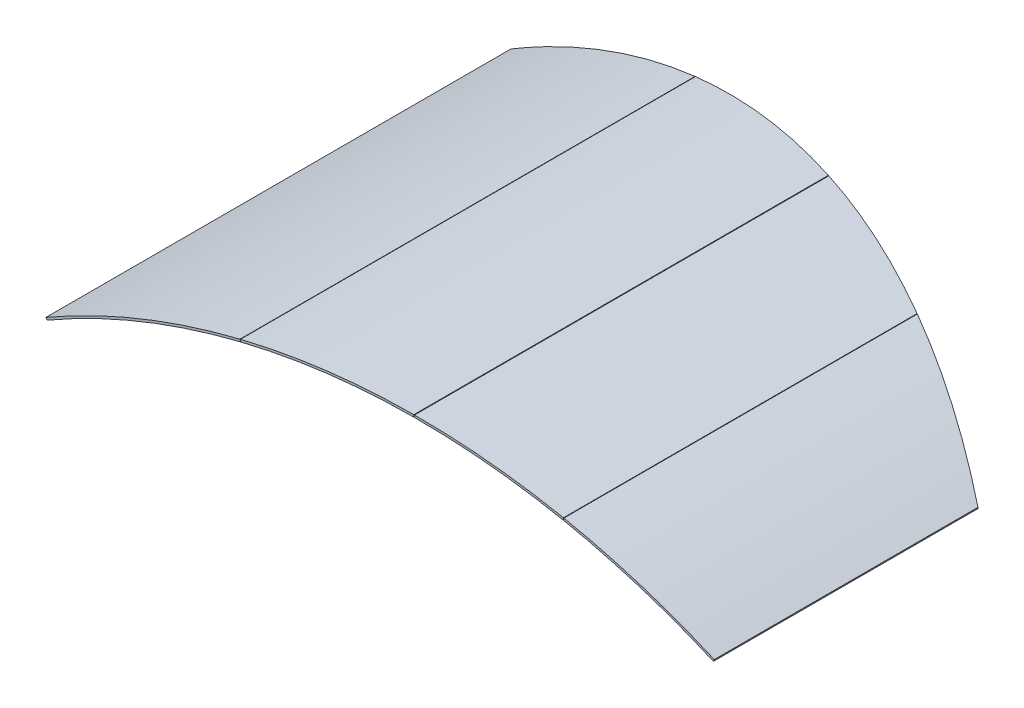
from build123d import *

# Parameters (mm, degrees)
BOSS_EXTRUDE1_DEPTH   = 3583.694422
BOSS_EXTRUDE1_2_DEPTH = 3583.694422
BOSS_EXTRUDE1_3_DEPTH = 3583.694422
BOSS_EXTRUDE1_4_DEPTH = 3583.694422
CUT_EXTRUDE1_DEPTH    = 10093.227131579


with BuildPart() as part:
    # Sketch1 → Boss-Extrude1 (new body)
    with BuildSketch(Plane.XY):
        with BuildLine():
            Line((-23335.251402241, -652.881922545), (-23342.758138859, -639.895433206))
            ThreePointArc((-23342.758138859, -639.895433206), (-22700.104960378, -326.691684273), (-22019.755739598, -107.090605176))
            Line((-22019.755739598, -107.090605176), (-22016.167075238, -121.654996276))
            ThreePointArc((-22016.167075238, -121.654996276), (-22694.501441466, -340.605726669), (-23335.251402241, -652.881922545))
        make_face()
    extrude(amount=-BOSS_EXTRUDE1_DEPTH)


with BuildPart() as body_2:
    # Sketch1 → Boss-Extrude1 2 (new body)
    with BuildSketch(Plane.XY):
        with BuildLine():
            Line((-18790.123490112, -395.665128297), (-18784.129846793, -381.914628678))
            ThreePointArc((-18784.129846793, -381.914628678), (-19288.54647688, -193.278110813), (-19810.140273885, -59.263994))
            Line((-19810.140273885, -59.263994), (-19813.095386818, -73.970023633))
            ThreePointArc((-19813.095386818, -73.970023633), (-19293.0462901, -207.587257573), (-18790.123490112, -395.665128297))
        make_face()
    extrude(amount=-BOSS_EXTRUDE1_2_DEPTH)


with BuildPart() as body_3:
    # Sketch1 → Boss-Extrude1 3 (new body)
    with BuildSketch(Plane.XY):
        with BuildLine():
            Line((-20829.194612545, 24.955453799), (-20829.194612545, 39.955585724))
            ThreePointArc((-20829.194612545, 39.955585724), (-20318.653824606, 16.307524828), (-19813.095386818, -58.671091552))
            Line((-19813.095386818, -58.671091552), (-19816.041748182, -73.378877065))
            ThreePointArc((-19816.041748182, -73.378877065), (-20320.13423627, 1.380724409), (-20829.194612545, 24.955453799))
        make_face()
    extrude(amount=-BOSS_EXTRUDE1_3_DEPTH)


with BuildPart() as body_4:
    # Sketch1 → Boss-Extrude1 4 (new body)
    with BuildSketch(Plane.XY):
        with BuildLine():
            Line((-20833.948404266, 24.933249016), (-20833.948404266, 39.933446702))
            ThreePointArc((-20833.948404266, 39.933446702), (-21429.456343968, 1.728199316), (-22016.338028454, -106.249740986))
            Line((-22016.338028454, -106.249740986), (-22012.749363226, -120.814135613))
            ThreePointArc((-22012.749363226, -120.814135613), (-21427.648836894, -13.162536936), (-20833.948404266, 24.933249016))
        make_face()
    extrude(amount=-BOSS_EXTRUDE1_4_DEPTH)


with BuildPart() as cut_extrude1_tool:
    # Sketch2 → Cut-Extrude1 (new body, through all)
    with BuildSketch(Plane(origin=(-13215.769587775, -9495.416647579, 12327.336037209), x_dir=(-0.998403381, -0.056486181, 0), z_dir=(-0.056486181, 0.998403381, 0))):
        with BuildLine():
            Line((4915.975271348, -14030.30481095), (4915.975271348, -16551.962367755))
            Line((4915.975271348, -16551.962367755), (9934.445108247, -16551.962367755))
            Line((9934.445108247, -16551.962367755), (9934.445108247, -15483.330555695))
            Line((9934.445108247, -15483.330555695), (9864.461322562, -15483.330555695))
            ThreePointArc((9864.461322562, -15483.330555695), (7256.210118512, -15213.201614697), (4915.975271348, -14030.30481095))
        make_face()
    extrude(amount=CUT_EXTRUDE1_DEPTH)


with BuildPart() as part_1:
    add(part.part)

    # Cut-Extrude1: cut by cut_extrude1_tool
    add(cut_extrude1_tool.part, mode=Mode.SUBTRACT)


with BuildPart() as body_2_1:
    add(body_2.part)

    # Cut-Extrude1: cut by cut_extrude1_tool
    add(cut_extrude1_tool.part, mode=Mode.SUBTRACT)


with BuildPart() as body_3_1:
    add(body_3.part)

    # Cut-Extrude1: cut by cut_extrude1_tool
    add(cut_extrude1_tool.part, mode=Mode.SUBTRACT)


with BuildPart() as body_4_1:
    add(body_4.part)

    # Cut-Extrude1: cut by cut_extrude1_tool
    add(cut_extrude1_tool.part, mode=Mode.SUBTRACT)


solid = Compound([part_1.part, body_2_1.part, body_3_1.part, body_4_1.part])
